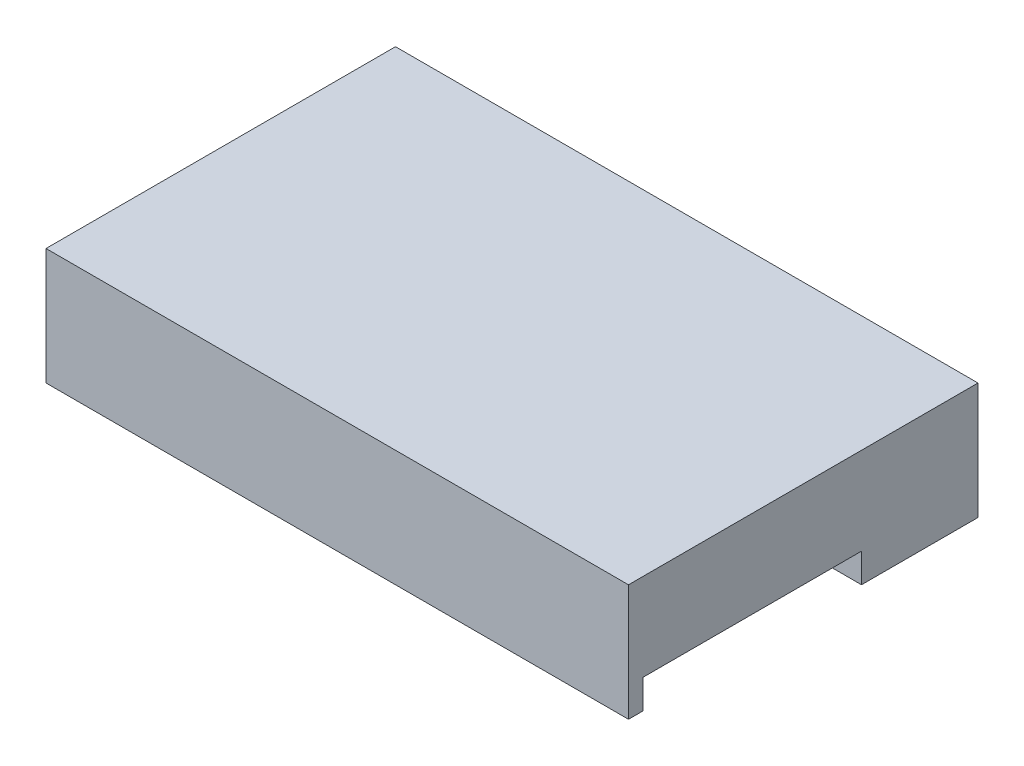
from build123d import *

# Parameters (mm, degrees)
SKETCH2_W           = 20
SKETCH2_H           = 12
BOSS_EXTRUDE1_DEPTH = 4
SKETCH3_W           = 20
SKETCH3_H           = 8
CUT_EXTRUDE1_DEPTH  = 1
SKETCH4_W           = 20
SKETCH4_H           = 0.5
BOSS_EXTRUDE2_DEPTH = 1


with BuildPart() as part:
    # Sketch2 → Boss-Extrude1 (new body)
    with BuildSketch(Plane(origin=(0, 0, 0), x_dir=(1, 0, 0), z_dir=(0, 1, 0))):
        Rectangle(SKETCH2_W, SKETCH2_H)
    extrude(amount=BOSS_EXTRUDE1_DEPTH)

    # Sketch3 → Cut-Extrude1 (cut)
    with BuildSketch(Plane.XZ):
        with Locations((0, 2)):
            Rectangle(SKETCH3_W, SKETCH3_H)
    extrude(amount=-CUT_EXTRUDE1_DEPTH, mode=Mode.SUBTRACT)

    # Sketch4 → Boss-Extrude2 (add)
    with BuildSketch(Plane.XZ.offset(-1)):
        with Locations((0, 5.75)):
            Rectangle(SKETCH4_W, SKETCH4_H)
    extrude(amount=BOSS_EXTRUDE2_DEPTH)


solid = part.part
